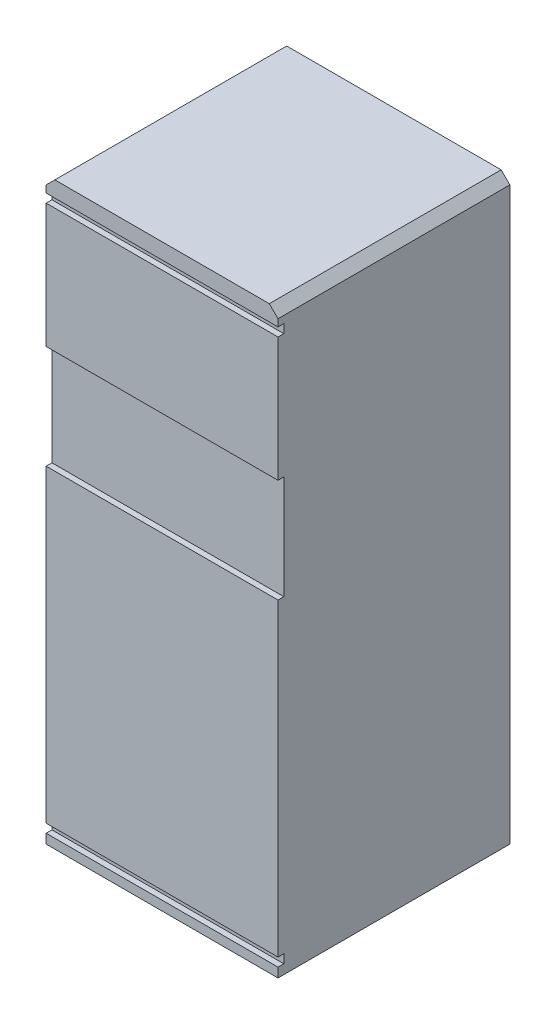
from build123d import *

# Parameters (mm, degrees)
CROQUIS1_W              = 800
CROQUIS1_H              = 800
SALIENTE_EXTRUIR1_DEPTH = 2000
CORTAR_EXTRUIR1_DEPTH   = 20
CHAFL_N1_SIZE           = 30


with BuildPart() as part:
    # Croquis1 → Saliente-Extruir1 (new body)
    with BuildSketch(Plane(origin=(0, 0, 0), x_dir=(1, 0, 0), z_dir=(0, 1, 0))):
        Rectangle(CROQUIS1_W, CROQUIS1_H)
    extrude(amount=SALIENTE_EXTRUIR1_DEPTH)

    # Croquis2 → Cortar-Extruir1 (cut)
    with BuildSketch(Plane.XY.offset(400)):
        with BuildLine():
            Line((-453.105485689, 1895.512731964), (-453.105485689, 82.602501534))
            ThreePointArc((-453.105485689, 82.602501534), (-438.460824748, 47.247162475), (-403.105485689, 32.602501534))
            Line((-403.105485689, 32.602501534), (426.238550511, 32.602501534))
            ThreePointArc((426.238550511, 32.602501534), (461.59388957, 47.247162475), (476.238550511, 82.602501534))
            Line((476.238550511, 82.602501534), (476.238550511, 1895.512731964))
            ThreePointArc((476.238550511, 1895.512731964), (461.59388957, 1930.868071024), (426.238550511, 1945.512731964))
            Line((426.238550511, 1945.512731964), (-403.105485689, 1945.512731964))
            ThreePointArc((-403.105485689, 1945.512731964), (-438.460824748, 1930.868071024), (-453.105485689, 1895.512731964))
        make_face()
        with BuildLine():
            Line((-403.105485689, 1915.512731964), (426.238550511, 1915.512731964))
            ThreePointArc((426.238550511, 1915.512731964), (440.380686134, 1909.654867588), (446.238550511, 1895.512731964))
            Line((446.238550511, 1895.512731964), (446.238550511, 1487.15617354))
            Line((446.238550511, 1487.15617354), (-423.105485689, 1487.15617354))
            Line((-423.105485689, 1487.15617354), (-423.105485689, 1895.512731964))
            ThreePointArc((-423.105485689, 1895.512731964), (-417.247621312, 1909.654867588), (-403.105485689, 1915.512731964))
        make_face(mode=Mode.SUBTRACT)
        with BuildLine():
            Line((-403.105485689, 62.602501534), (426.238550511, 62.602501534))
            ThreePointArc((426.238550511, 62.602501534), (440.380686134, 68.460365911), (446.238550511, 82.602501534))
            Line((446.238550511, 82.602501534), (446.238550511, 1129.448445192))
            Line((446.238550511, 1129.448445192), (-423.105485689, 1129.448445192))
            Line((-423.105485689, 1129.448445192), (-423.105485689, 82.602501534))
            ThreePointArc((-423.105485689, 82.602501534), (-417.247621312, 68.460365911), (-403.105485689, 62.602501534))
        make_face(mode=Mode.SUBTRACT)
    extrude(amount=-CORTAR_EXTRUIR1_DEPTH, mode=Mode.SUBTRACT)

    # Chaflán1
    chafl_n1_edges = [part.edges().sort_by_distance(p)[0] for p in [
        (-400, 2000, 0),
        (400, 2000, 0),
    ]]
    chamfer(chafl_n1_edges, length=CHAFL_N1_SIZE)


solid = part.part
